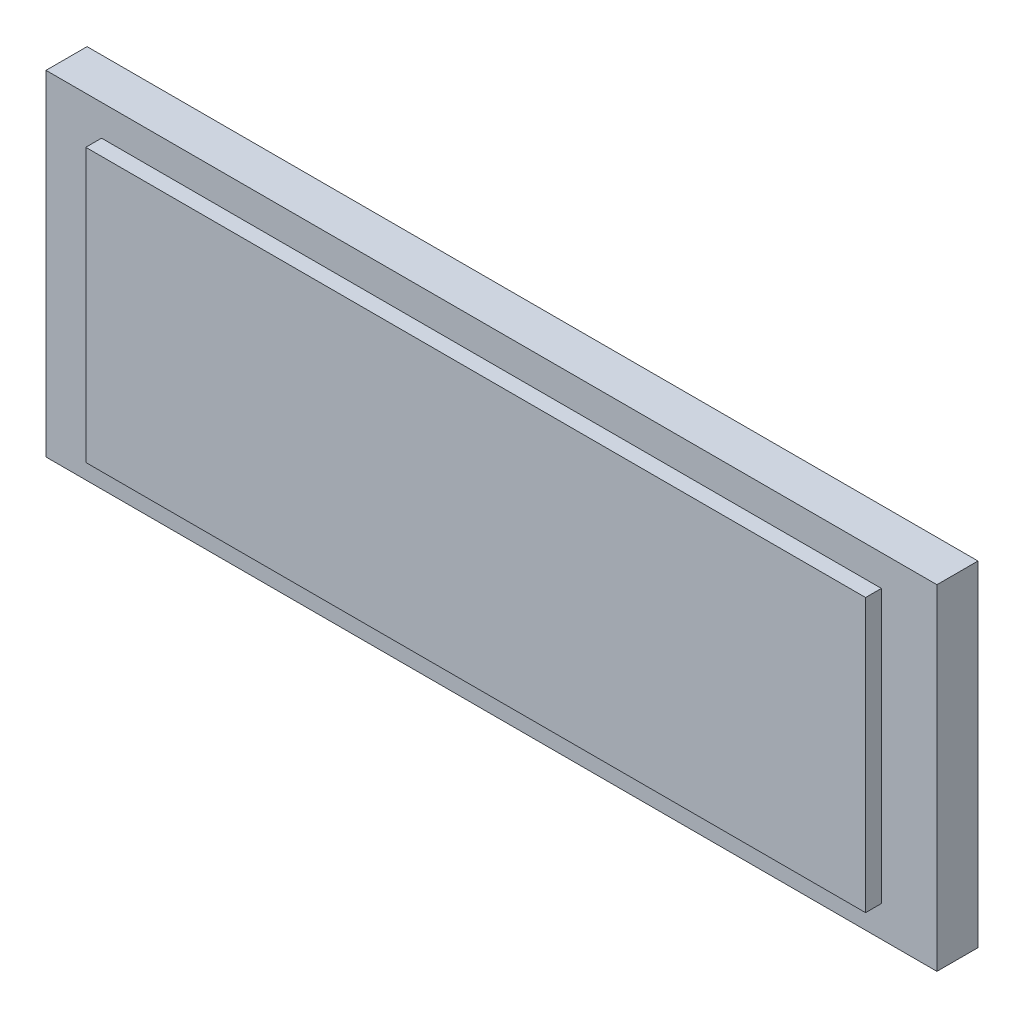
from build123d import *

# Parameters (mm, degrees)
SKETCH1_W           = 71.628
SKETCH1_H           = 26.924
BOSS_EXTRUDE1_DEPTH = 3.302
SKETCH2_W           = 62.695893944
SKETCH2_H           = 21.94356288
BOSS_EXTRUDE2_DEPTH = 1.27


with BuildPart() as part:
    # Sketch1 → Boss-Extrude1 (new body)
    with BuildSketch(Plane.XY):
        with Locations((35.814, 13.462)):
            Rectangle(SKETCH1_W, SKETCH1_H)
    extrude(amount=BOSS_EXTRUDE1_DEPTH)

    # Sketch2 → Boss-Extrude2 (add)
    with BuildSketch(Plane.XY.offset(3.302)):
        with Locations((35.814, 13.462)):
            Rectangle(SKETCH2_W, SKETCH2_H)
    extrude(amount=BOSS_EXTRUDE2_DEPTH)


solid = part.part
